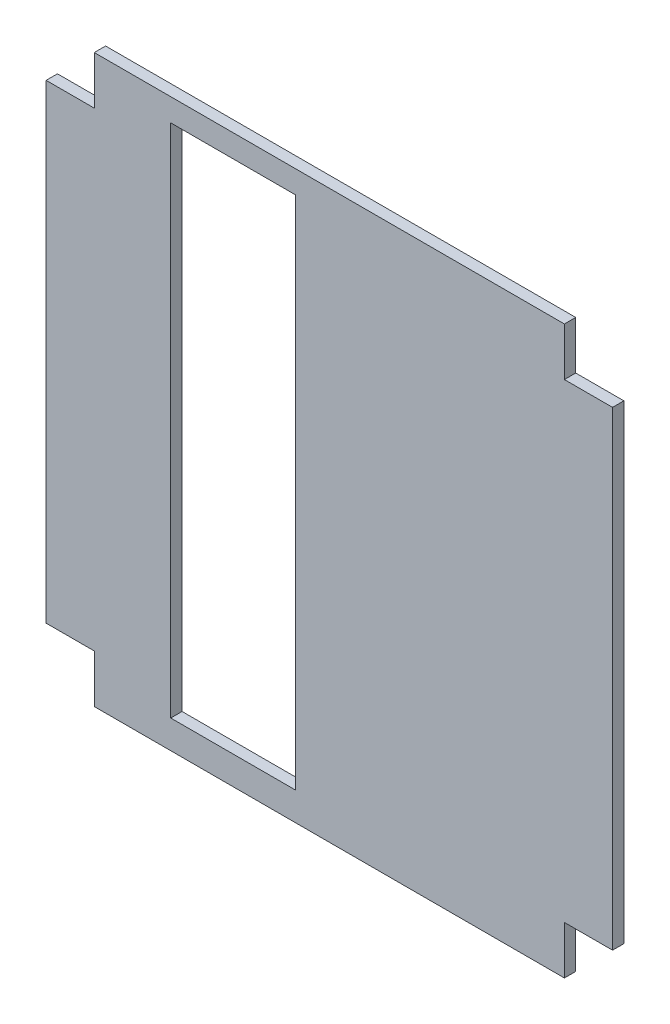
from build123d import *

# Parameters (mm, degrees)
BOSS_EXTRUDE1_DEPTH = 2
SKETCH1_5_W         = 22
SKETCH1_5_H         = 91
CUT_EXTRUDE1_DEPTH  = 141.021426932


with BuildPart() as part:
    # Sketch1 → Boss-Extrude1 (new body)
    with BuildSketch(Plane.XY):
        Polygon((-99, 90.5), (-99, 7.5), (-90.5, 7.5), (-90.5, -1), (-7.5, -1), (-7.5, 7.5), (1, 7.5), (1, 90.5), (-7.5, 90.5), (-7.5, 99), (-90.5, 99), (-90.5, 90.5), align=None)
    extrude(amount=BOSS_EXTRUDE1_DEPTH)

    # Sketch1_5 → Cut-Extrude1 (cut, through all)
    with BuildSketch(Plane.XY):
        with Locations((-66, 49.5)):
            Rectangle(SKETCH1_5_W, SKETCH1_5_H)
    extrude(amount=CUT_EXTRUDE1_DEPTH, mode=Mode.SUBTRACT)


solid = part.part
